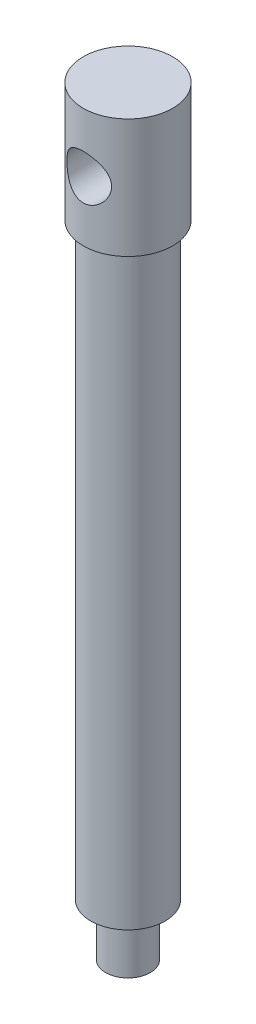
from build123d import *

# Parameters (mm, degrees)
SKETCH1_R           = 6
BOSS_EXTRUDE1_DEPTH = 8
SKETCH2_R           = 5
BOSS_EXTRUDE2_DEPTH = 79
SKETCH3_R           = 3
BOSS_EXTRUDE3_DEPTH = 7
SKETCH4_R           = 3
CUT_EXTRUDE1_DEPTH  = 8.5


with BuildPart() as part:
    # Sketch1 → Boss-Extrude1 (new body, symmetric)
    with BuildSketch(Plane(origin=(0, 0, 0), x_dir=(1, 0, 0), z_dir=(0, 1, 0))):
        Circle(SKETCH1_R)
    extrude(amount=BOSS_EXTRUDE1_DEPTH, both=True)

    # Sketch2 → Boss-Extrude2 (add)
    with BuildSketch(Plane.XZ.offset(8)):
        Circle(SKETCH2_R)
    extrude(amount=BOSS_EXTRUDE2_DEPTH)

    # Sketch3 → Boss-Extrude3 (add)
    with BuildSketch(Plane.XZ.offset(87)):
        Circle(SKETCH3_R)
    extrude(amount=BOSS_EXTRUDE3_DEPTH)

    # Sketch4 → Cut-Extrude1 (cut, symmetric)
    with BuildSketch(Plane.XY):
        Circle(SKETCH4_R)
    extrude(amount=CUT_EXTRUDE1_DEPTH, both=True, mode=Mode.SUBTRACT)


solid = part.part
